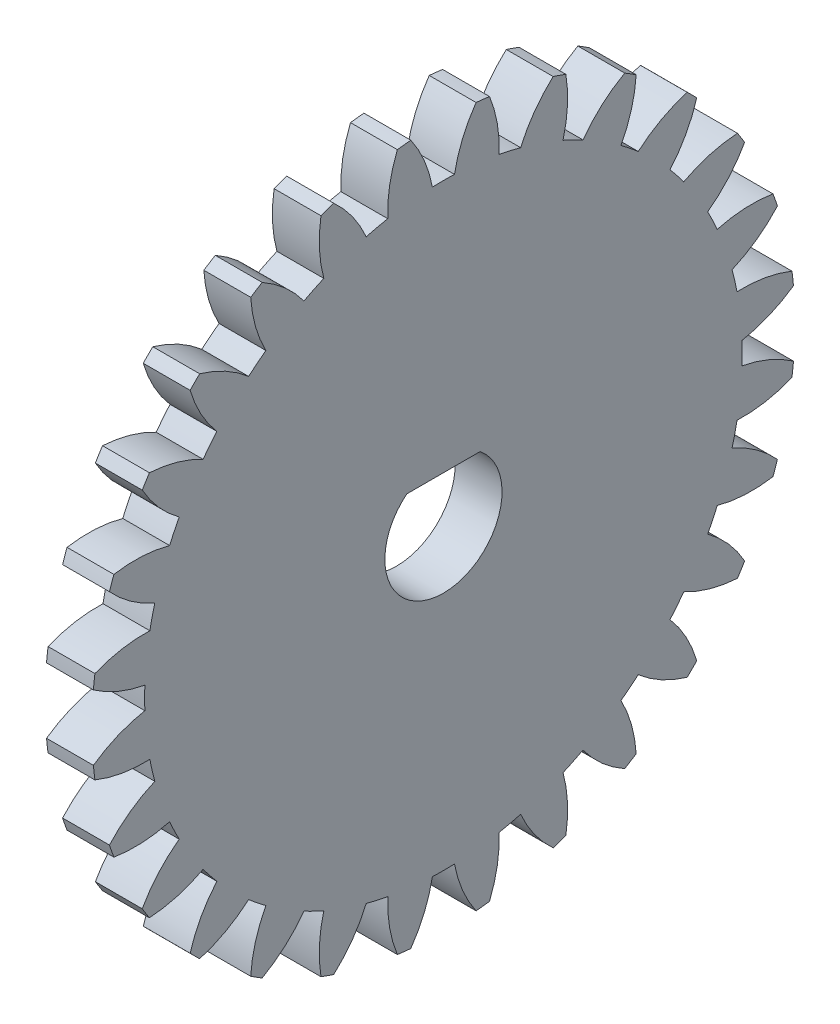
from build123d import *

# Parameters (mm, degrees)
BASPROSKE_W        = 2
BASPROSKE_H        = 15
TOOTHCUT_DEPTH     = 22.307275753
TEETHCUTS_COUNT    = 28
TEETHCUTS_ANGLE    = 347.142857143
BORSKE_R           = 1.5
BORE_DEPTH         = 50.0000508
CUT_EXTRUDE1_DEPTH = 10


with BuildPart() as part:
    # BasProSke → Base-Revolve (revolve)
    with BuildSketch(Plane(origin=(0, 0, 0), x_dir=(1, 0, 0), z_dir=(0, 1, 0)), mode=Mode.PRIVATE) as base_revolve_sk:
        with Locations((1, 7.5)):
            Rectangle(BASPROSKE_W, BASPROSKE_H)
    revolve(base_revolve_sk.sketch.rotate(Axis((-10, 0, 0), (1, 0, 0)), 180), axis=Axis((-10, 0, 0), (1, 0, 0)))

    # TooCutSke → ToothCut (cut, through all)
    with BuildSketch(Plane(origin=(0, 0, 0), x_dir=(0, 0, -1), z_dir=(1, 0, 0))):
        with BuildLine():
            ThreePointArc((0.471336039, 12.740284272), (0, 12.749), (-0.471336039, 12.740284272))
            ThreePointArc((-0.471336039, 12.740284272), (-0.81983923, 13.900763331), (-1.409805137, 14.959114099))
            ThreePointArc((-1.409805137, 14.959114099), (0, 15.0254), (1.409805137, 14.959114099))
            ThreePointArc((1.409805137, 14.959114099), (0.81983923, 13.900763331), (0.471336039, 12.740284272))
        make_face()
    toothcut = extrude(amount=TOOTHCUT_DEPTH, mode=Mode.SUBTRACT)

    # TeethCuts: ToothCut ×28 about axis
    teethcuts_axis = Axis((-10, 0, 0), (1, 0, 0))
    for i in range(1, TEETHCUTS_COUNT):
        add(toothcut.rotate(teethcuts_axis, i * TEETHCUTS_ANGLE / (TEETHCUTS_COUNT - 1)), mode=Mode.SUBTRACT)

    # BorSke → Bore (cut, symmetric)
    with BuildSketch(Plane(origin=(0, 0, 0), x_dir=(0, 0, -1), z_dir=(1, 0, 0))):
        with Locations(Location((0, 0, 0), (0, 0, 180))):
            Circle(BORSKE_R)
    extrude(amount=BORE_DEPTH, both=True, mode=Mode.SUBTRACT)

    # Sketch1 → Cut-Extrude1 (cut)
    with BuildSketch(Plane(origin=(2, 0, 0), x_dir=(0, 0, -1), z_dir=(1, 0, 0))):
        with BuildLine():
            Line((0, 1.95), (1.564448785, 1.95))
            ThreePointArc((1.564448785, 1.95), (0, -2.5), (-1.564448785, 1.95))
            Line((-1.564448785, 1.95), (0, 1.95))
        make_face()
    extrude(amount=-CUT_EXTRUDE1_DEPTH, mode=Mode.SUBTRACT)


solid = part.part
